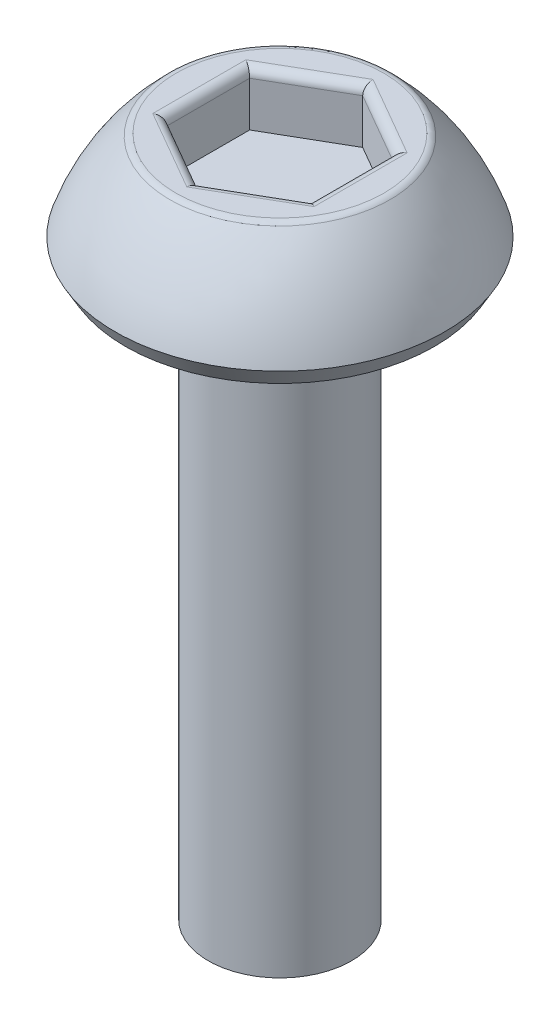
from build123d import *

# Parameters (mm, degrees)
CUT_EXTRUDE1_DEPTH = 0.75
FILLET1_R          = 0.125


with BuildPart() as part:
    # Sketch1 → Revolve1 (revolve)
    with BuildSketch(Plane(origin=(0, 0, 0), x_dir=(0, 0, -1), z_dir=(1, 0, 0))):
        with BuildLine():
            Line((0, 1.5), (-1.5, 1.5))
            ThreePointArc((-1.5, 1.5), (-1.978515811, 0.925250119), (-2.3, 0.25))
            Line((-2.3, 0.25), (-2.155662433, 0))
            Line((-2.155662433, 0), (-1, 0))
            Line((-1, 0), (-1, -8))
            Line((-1, -8), (0, -8))
            Line((0, -8), (0, 1.5))
        make_face()
    revolve(axis=Axis((0, -8, 0), (0, 1, 0)))

    # Sketch2 → Cut-Extrude1 (cut)
    with BuildSketch(Plane(origin=(0, 1.5, 0), x_dir=(1, 0, 0), z_dir=(0, 1, 0))):
        Polygon((0, 1.154700538), (-1, 0.577350269), (-1, -0.577350269), (0, -1.154700538), (1, -0.577350269), (1, 0.577350269), align=None)
    extrude(amount=-CUT_EXTRUDE1_DEPTH, mode=Mode.SUBTRACT)

    # Fillet1
    fillet1_edges = [part.edges().sort_by_distance(p)[0] for p in [
        (0.5, 1.5, -0.866025404),
        (-0.5, 1.5, -0.866025404),
        (-1, 1.5, 0),
        (-0.5, 1.5, 0.866025404),
        (0.5, 1.5, 0.866025404),
        (1, 1.5, 0),
        (0, 1.5, -1.5),
    ]]
    fillet(fillet1_edges, radius=FILLET1_R)


solid = part.part
